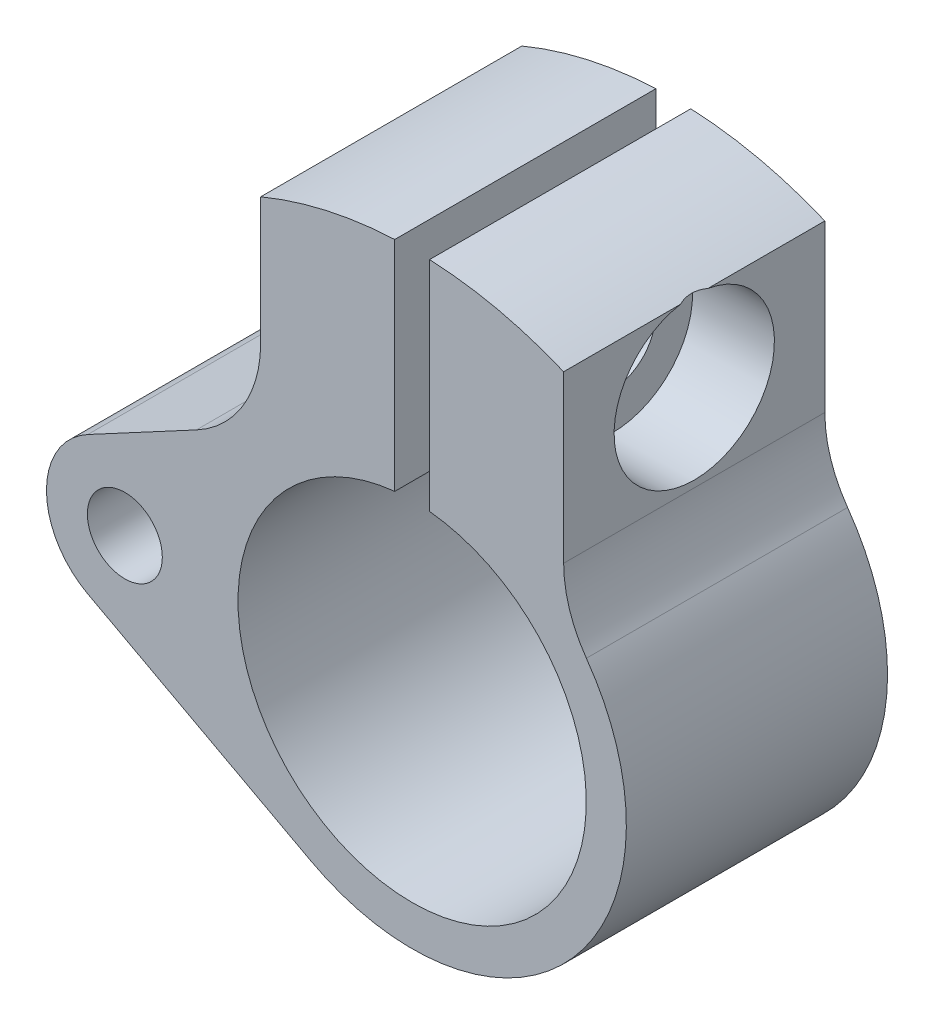
from build123d import *

# Parameters (mm, degrees)
SKETCH1_R                 = 10
BOSS_EXTRUDE1_DEPTH       = 7.5
FILLET1_R                 = 7
CUT_EXTRUDE1_DEPTH        = 16
CUT_EXTRUDE2_START        = 3
SKETCH3_R                 = 4.60375
CUT_EXTRUDE2_DEPTH        = 15
F_8_CLEARANCE_HOLE1_D     = 4.9149
F_8_CLEARANCE_HOLE1_DEPTH = 3
F_8_32_TAPPED_HOLE1_D     = 3.4544
F_8_CLEARANCE_HOLE2_D     = 4.3053
F_8_CLEARANCE_HOLE2_DEPTH = 15


with BuildPart() as part:
    # Sketch1 → Boss-Extrude1 (new body, symmetric)
    with BuildSketch(Plane.XY):
        with BuildLine():
            Line((-8.7, 20.749939759), (-8.7, 9.290956753))
            Line((-8.7, 9.290956753), (-18.627272727, 3.96543954))
            ThreePointArc((-18.627272727, 3.96543954), (-21, 0), (-18.627272727, -3.96543954))
            Line((-18.627272727, -3.96543954), (-5.814545455, -10.838868075))
            ThreePointArc((-5.814545455, -10.838868075), (9.872829559, -7.336023207), (8.7, 8.694826048))
            Line((8.7, 8.694826048), (8.7, 20.749939759))
            ThreePointArc((8.7, 20.749939759), (0, 22.5), (-8.7, 20.749939759))
        make_face()
        Circle(SKETCH1_R, mode=Mode.SUBTRACT)
    extrude(amount=BOSS_EXTRUDE1_DEPTH, both=True)

    # Fillet1
    fillet1_edges = [part.edges().sort_by_distance(p)[0] for p in [
        (8.7, 8.694826048, 0),
        (-8.7, 9.290956753, 0),
    ]]
    fillet(fillet1_edges, radius=FILLET1_R)

    # Sketch2 → Cut-Extrude1 (cut, through all)
    with BuildSketch(Plane.XY.offset(7.5)):
        with BuildLine():
            Line((-1, 22.477766793), (-1, 9.949874371))
            ThreePointArc((-1, 9.949874371), (0, 10), (1, 9.949874371))
            Line((1, 9.949874371), (1, 22.477766793))
            ThreePointArc((1, 22.477766793), (0, 22.5), (-1, 22.477766793))
        make_face()
    extrude(amount=-CUT_EXTRUDE1_DEPTH, mode=Mode.SUBTRACT)

    # Sketch3 → Cut-Extrude2 (cut)
    with BuildSketch(Plane(origin=(1, 0, 0), x_dir=(0, 0, -1), z_dir=(1, 0, 0)).offset(CUT_EXTRUDE2_START)):
        with Locations(Location((0, 16.213820582, 0), (0, 0, 80.166973696))):  # turned: the seam where the file's is
            Circle(SKETCH3_R)
    extrude(amount=CUT_EXTRUDE2_DEPTH, mode=Mode.SUBTRACT)

    # #8 Clearance Hole1
    with Locations(Plane(origin=(4, 0, 0), x_dir=(0, 0, -1), z_dir=(1, 0, 0))):
        with Locations((0, 16.213820582)):
            Hole(F_8_CLEARANCE_HOLE1_D / 2, depth=F_8_CLEARANCE_HOLE1_DEPTH)

    # #8-32 Tapped Hole1 (through all)
    with Locations(Plane(origin=(-1, 1.097851263, -6.242435486), x_dir=(0, 0, 1), z_dir=(1, 0, 0))):
        with Locations((6.242435486, -15.115969319)):
            Hole(F_8_32_TAPPED_HOLE1_D / 2)

    # #8 Clearance Hole2
    with Locations(Plane.XY.offset(7.5)):
        with Locations((-16.5, 0)):
            Hole(F_8_CLEARANCE_HOLE2_D / 2, depth=F_8_CLEARANCE_HOLE2_DEPTH)


solid = part.part
